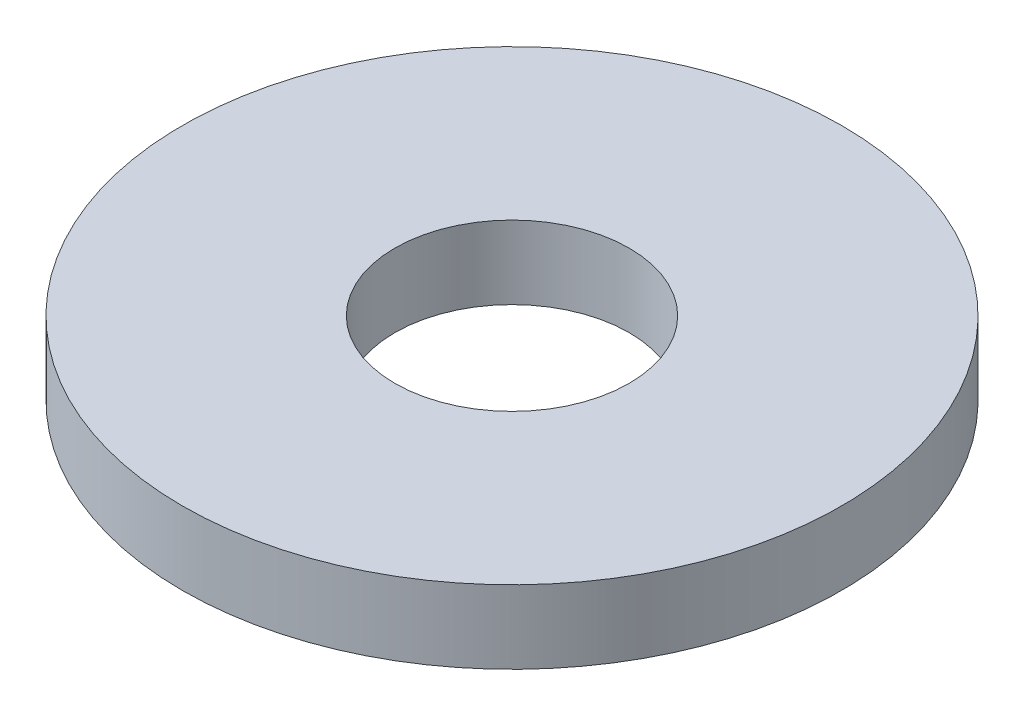
from build123d import *

# Parameters (mm, degrees)
SKETCH1_R           = 4.5
SKETCH1_R_2         = 1.6
BOSS_EXTRUDE1_DEPTH = 0.5


with BuildPart() as part:
    # Sketch1 → Boss-Extrude1 (new body, symmetric)
    with BuildSketch(Plane(origin=(0, 0, 0), x_dir=(1, 0, 0), z_dir=(0, 1, 0))):
        Circle(SKETCH1_R)
        Circle(SKETCH1_R_2, mode=Mode.SUBTRACT)
    extrude(amount=BOSS_EXTRUDE1_DEPTH, both=True)


solid = part.part
